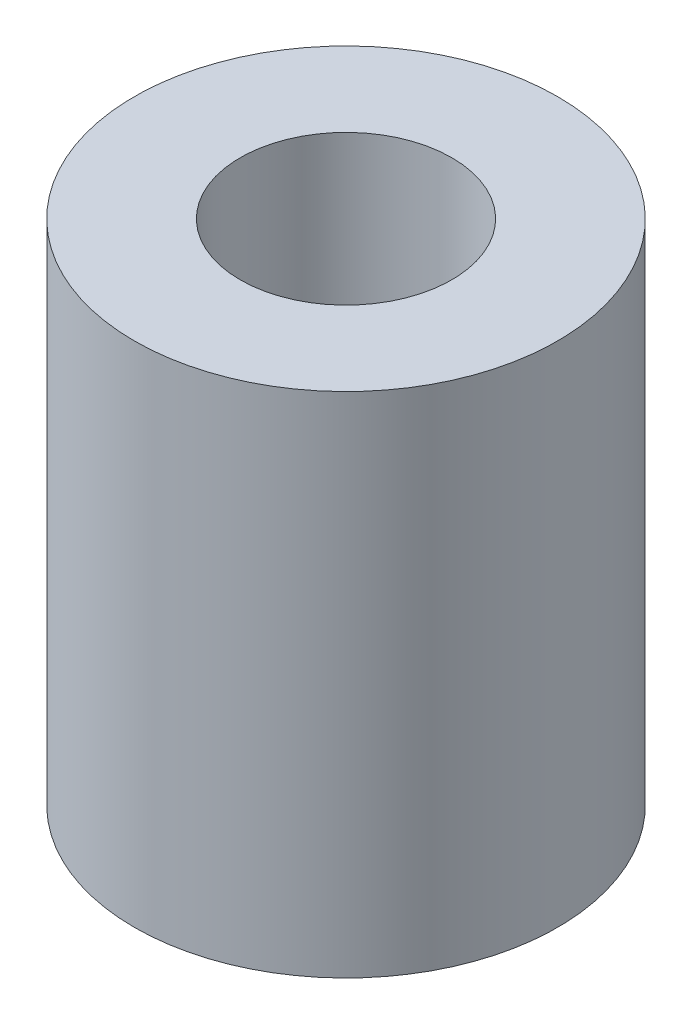
from build123d import *

# Parameters (mm, degrees)
SKETCH_1_R          = 10
EXTRUDE_1_DEPTH     = 24
SKETCH_3_R          = 5
CUT_EXTRUDE_1_DEPTH = 12
SKETCH_4_R          = 2.5
CUT_EXTRUDE_2_DEPTH = 12


with BuildPart() as part:
    # 草图1 → 凸台-拉伸1 (new body)
    with BuildSketch(Plane(origin=(0, 0, 0), x_dir=(1, 0, 0), z_dir=(0, 1, 0))):
        Circle(SKETCH_1_R)
    extrude(amount=EXTRUDE_1_DEPTH)

    # 草图3 → 切除-拉伸1 (cut)
    with BuildSketch(Plane(origin=(0, 24, 0), x_dir=(1, 0, 0), z_dir=(0, 1, 0))):
        Circle(SKETCH_3_R)
    extrude(amount=-CUT_EXTRUDE_1_DEPTH, mode=Mode.SUBTRACT)

    # 草图4 → 切除-拉伸2 (cut)
    with BuildSketch(Plane.XZ):
        Circle(SKETCH_4_R)
    extrude(amount=-CUT_EXTRUDE_2_DEPTH, mode=Mode.SUBTRACT)


solid = part.part
